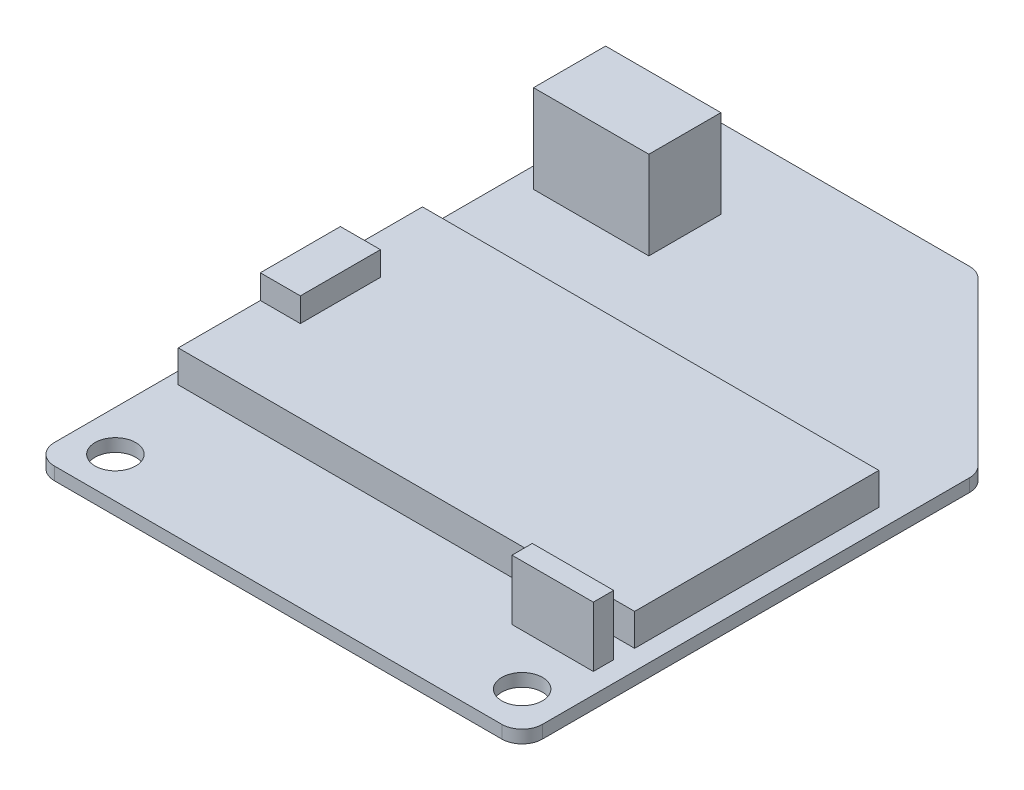
from build123d import *

# Parameters (mm, degrees)
BOARD_DEPTH            = 1.6
BOARDSKETCH_3_R        = 2.54
BOARD_HOLES_DEPTH      = 1.6
PORT_SKETCH_W          = 14.4
PORT_SKETCH_H          = 9
BARREL_CONN_DEPTH      = 11
BARREL_SKETCH_R        = 3.25
BARREL_CONN_HOLE_DEPTH = 9
PORTSKETCH_3_W         = 10.16
PORTSKETCH_3_H         = 2.54
PIN_HEADER_DEPTH       = 7.5
PORTSKETCH_4_W         = 57
PORTSKETCH_4_H         = 30.5
ESP8266_DEPTH          = 4
USB_SKETCH_W           = 5
USB_SKETCH_H           = 10
USB_PORT_DEPTH         = 3
LM7805_SKETCH_W        = 4.64
LM7805_SKETCH_H        = 10.24
LM7805_TH_DEPTH        = 9.07


with BuildPart() as part:
    # Board_Sketch → Board (new body)
    with BuildSketch(Plane(origin=(0, 0, 0), x_dir=(1, 0, 0), z_dir=(0, 1, 0))):
        with BuildLine():
            Line((30.48, -36.83), (30.48, 16.51))
            ThreePointArc((30.48, 16.51), (30.286654013, 17.482015918), (29.736051224, 18.306051224))
            Line((29.736051224, 18.306051224), (9.416051224, 38.626051224))
            ThreePointArc((9.416051224, 38.626051224), (8.592015918, 39.176654013), (7.62, 39.37))
            Line((7.62, 39.37), (-27.94, 39.37))
            ThreePointArc((-27.94, 39.37), (-29.736051224, 38.626051224), (-30.48, 36.83))
            Line((-30.48, 36.83), (-30.48, -36.83))
            ThreePointArc((-30.48, -36.83), (-29.736051224, -38.626051224), (-27.94, -39.37))
            Line((-27.94, -39.37), (27.94, -39.37))
            ThreePointArc((27.94, -39.37), (29.736051224, -38.626051224), (30.48, -36.83))
        make_face()
    extrude(amount=BOARD_DEPTH)

    # BoardSketch_3 → Board_Holes (cut)
    with BuildSketch(Plane(origin=(0, 0, 0), x_dir=(1, 0, 0), z_dir=(0, 1, 0))):
        with Locations((-25.400144884, -34.290144884)):
            Circle(BOARDSKETCH_3_R)
        with Locations((25.400144884, -34.290144884)):
            Circle(BOARDSKETCH_3_R)
        with Locations((-25.400144884, 34.290144884)):
            Circle(BOARDSKETCH_3_R)
    extrude(amount=BOARD_HOLES_DEPTH, mode=Mode.SUBTRACT)

    # Port_Sketch → Barrel_Conn (add)
    with BuildSketch(Plane(origin=(0, 1.6, 0), x_dir=(1, 0, 0), z_dir=(0, 1, 0))):
        with Locations((-20.737, 24.97)):
            Rectangle(PORT_SKETCH_W, PORT_SKETCH_H)
    extrude(amount=BARREL_CONN_DEPTH)

    # Barrel_Sketch → Barrel_Conn_Hole (cut)
    with BuildSketch(Plane.ZY.offset(27.937)):
        with Locations((-24.97, 8.1)):
            Circle(BARREL_SKETCH_R)
    extrude(amount=-BARREL_CONN_HOLE_DEPTH, mode=Mode.SUBTRACT)

    # PortSketch_3 → Pin_Header (add)
    with BuildSketch(Plane(origin=(0, 1.6, 0), x_dir=(1, 0, 0), z_dir=(0, 1, 0))):
        with Locations((22.86, -26.67)):
            Rectangle(PORTSKETCH_3_W, PORTSKETCH_3_H)
    extrude(amount=PIN_HEADER_DEPTH)

    # PortSketch_4 → ESP8266 (add)
    with BuildSketch(Plane(origin=(0, 1.6, 0), x_dir=(1, 0, 0), z_dir=(0, 1, 0))):
        with Locations((-0.48, -7.61)):
            Rectangle(PORTSKETCH_4_W, PORTSKETCH_4_H)
    extrude(amount=ESP8266_DEPTH)

    # USB_Sketch → USB_Port (add)
    with BuildSketch(Plane(origin=(0, 5.6, 0), x_dir=(1, 0, 0), z_dir=(0, 1, 0))):
        with Locations((-26.48, -7.61)):
            Rectangle(USB_SKETCH_W, USB_SKETCH_H)
    extrude(amount=USB_PORT_DEPTH)

    # LM7805_Sketch → LM7805_TH (add)
    with BuildSketch(Plane.XZ):
        with Locations((-1.685, -5.04)):
            Rectangle(LM7805_SKETCH_W, LM7805_SKETCH_H)
    extrude(amount=LM7805_TH_DEPTH)


solid = part.part
